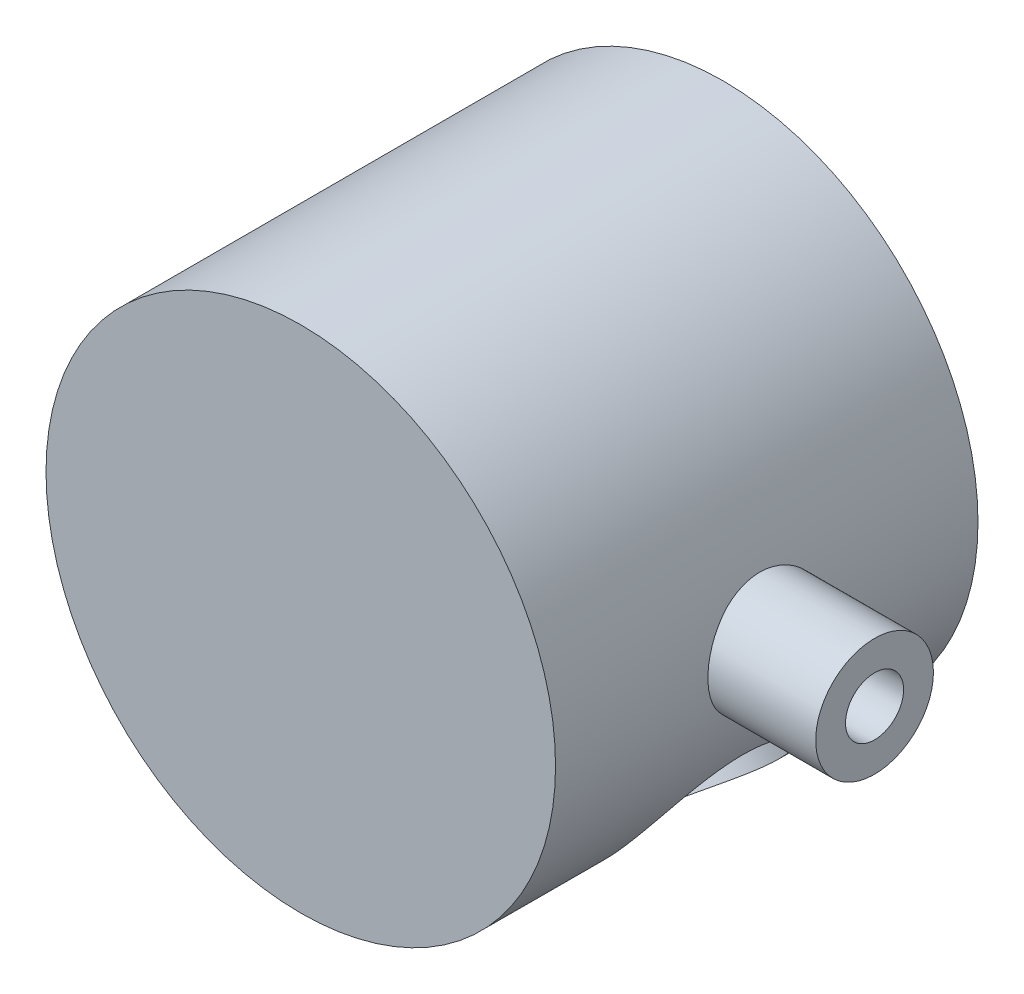
from build123d import *

# Parameters (mm, degrees)
SKETCH1_R                = 24.123
BOSS_EXTRUDE1_DEPTH      = 35
BOSS_EXTRUDE1_DEPTH_BACK = 5
SKETCH2_R                = 3.25
CUT_EXTRUDE2_DEPTH       = 19.25
SKETCH7_R                = 17.25
CUT_EXTRUDE10_DEPTH      = 30
CUT_EXTRUDE11_START      = 19.25
SKETCH8_R                = 2.75
CUT_EXTRUDE11_DEPTH      = 24.873
BOSS_EXTRUDE2_START      = 23.125
SKETCH9_R                = 5.575
BOSS_EXTRUDE2_DEPTH      = 11.203
CUT_EXTRUDE12_DEPTH      = 50
SKETCH4_R                = 2.75
CUT_EXTRUDE3_DEPTH       = 200
CUT_EXTRUDE9_START       = -24.123
SKETCH6_R                = 5.25
CUT_EXTRUDE9_DEPTH       = 4.533
CUT_EXTRUDE14_START      = -24.125
SKETCH12_R               = 8.25
CUT_EXTRUDE14_DEPTH      = 2
SKETCH13_R               = 3.25
CUT_EXTRUDE15_DEPTH      = 19.09
CIRPATTERN3_COUNT        = 2
CIRPATTERN3_ANGLE        = 90


with BuildPart() as part:
    # Sketch1 → Boss-Extrude1 (new body, two sides)
    with BuildSketch(Plane.XY) as boss_extrude1_sk:
        Circle(SKETCH1_R)
    extrude(amount=BOSS_EXTRUDE1_DEPTH)
    extrude(boss_extrude1_sk.sketch, amount=-BOSS_EXTRUDE1_DEPTH_BACK)

    # Sketch2 → Cut-Extrude2 (cut)
    with BuildSketch(Plane(origin=(0, 0, 0), x_dir=(0, 0, -1), z_dir=(1, 0, 0))):
        with Locations((-15, 0)):
            Circle(SKETCH2_R)
    extrude(amount=CUT_EXTRUDE2_DEPTH, mode=Mode.SUBTRACT)

    # Sketch7 → Cut-Extrude10 (cut)
    with BuildSketch(Plane(origin=(0, 0, -5), x_dir=(-1, 0, 0), z_dir=(0, 0, -1))):
        Circle(SKETCH7_R)
    extrude(amount=-CUT_EXTRUDE10_DEPTH, mode=Mode.SUBTRACT)

    # Sketch8 → Cut-Extrude11 (cut)
    with BuildSketch(Plane(origin=(0, 0, 0), x_dir=(0, 0, -1), z_dir=(1, 0, 0)).offset(CUT_EXTRUDE11_START)):
        with Locations((-15, 0)):
            Circle(SKETCH8_R)
    extrude(amount=CUT_EXTRUDE11_DEPTH, mode=Mode.SUBTRACT)

    # Sketch4 → Cut-Extrude3 (cut)
    with BuildSketch(Plane(origin=(0, 0, 0), x_dir=(0.707106781, 0.707106781, 0), z_dir=(-0.707106781, 0.707106781, 0))):
        with Locations((0, -15)):
            Circle(SKETCH4_R)
    cut_extrude3 = extrude(amount=-CUT_EXTRUDE3_DEPTH, mode=Mode.SUBTRACT)

    # Sketch6 → Cut-Extrude9 (cut)
    with BuildSketch(Plane(origin=(0, 0, 0), x_dir=(0.707106781, 0.707106781, 0), z_dir=(-0.707106781, 0.707106781, 0)).offset(CUT_EXTRUDE9_START)):
        with Locations((0, -15)):
            Circle(SKETCH6_R)
    cut_extrude9 = extrude(amount=CUT_EXTRUDE9_DEPTH, mode=Mode.SUBTRACT)

    # Sketch12 → Cut-Extrude14 (cut)
    with BuildSketch(Plane(origin=(0, 0, 0), x_dir=(0.707106781, 0.707106781, 0), z_dir=(-0.707106781, 0.707106781, 0)).offset(CUT_EXTRUDE14_START)):
        with Locations((0, -15)):
            Circle(SKETCH12_R)
    cut_extrude14 = extrude(amount=CUT_EXTRUDE14_DEPTH, mode=Mode.SUBTRACT)

    # Sketch13 → Cut-Extrude15 (cut)
    with BuildSketch(Plane(origin=(0, 0, 0), x_dir=(0.707106781, 0.707106781, 0), z_dir=(-0.707106781, 0.707106781, 0))):
        with Locations((0, -15)):
            Circle(SKETCH13_R)
    cut_extrude15 = extrude(amount=-CUT_EXTRUDE15_DEPTH, mode=Mode.SUBTRACT)

    # CirPattern3: Cut-Extrude3, Cut-Extrude9, Cut-Extrude14, Cut-Extrude15 ×2 about axis
    cirpattern3_axis = Axis((0, 0, -5), (0, 0, -1))
    for i in range(1, CIRPATTERN3_COUNT):
        add(cut_extrude3.rotate(cirpattern3_axis, i * CIRPATTERN3_ANGLE / (CIRPATTERN3_COUNT - 1)), mode=Mode.SUBTRACT)
        add(cut_extrude9.rotate(cirpattern3_axis, i * CIRPATTERN3_ANGLE / (CIRPATTERN3_COUNT - 1)), mode=Mode.SUBTRACT)
        add(cut_extrude14.rotate(cirpattern3_axis, i * CIRPATTERN3_ANGLE / (CIRPATTERN3_COUNT - 1)), mode=Mode.SUBTRACT)
        add(cut_extrude15.rotate(cirpattern3_axis, i * CIRPATTERN3_ANGLE / (CIRPATTERN3_COUNT - 1)), mode=Mode.SUBTRACT)


with BuildPart() as body_2:
    # Sketch9 → Boss-Extrude2 (new body)
    with BuildSketch(Plane(origin=(0, 0, 0), x_dir=(0, 0, -1), z_dir=(1, 0, 0)).offset(BOSS_EXTRUDE2_START)):
        with Locations((-15, 0)):
            Circle(SKETCH9_R)
    extrude(amount=BOSS_EXTRUDE2_DEPTH)

    # Sketch8 → Cut-Extrude12 (cut)
    with BuildSketch(Plane(origin=(0, 0, 0), x_dir=(0, 0, -1), z_dir=(1, 0, 0))):
        with Locations((-15, 0)):
            Circle(SKETCH8_R)
    extrude(amount=CUT_EXTRUDE12_DEPTH, mode=Mode.SUBTRACT)


solid = Compound([part.part, body_2.part])
